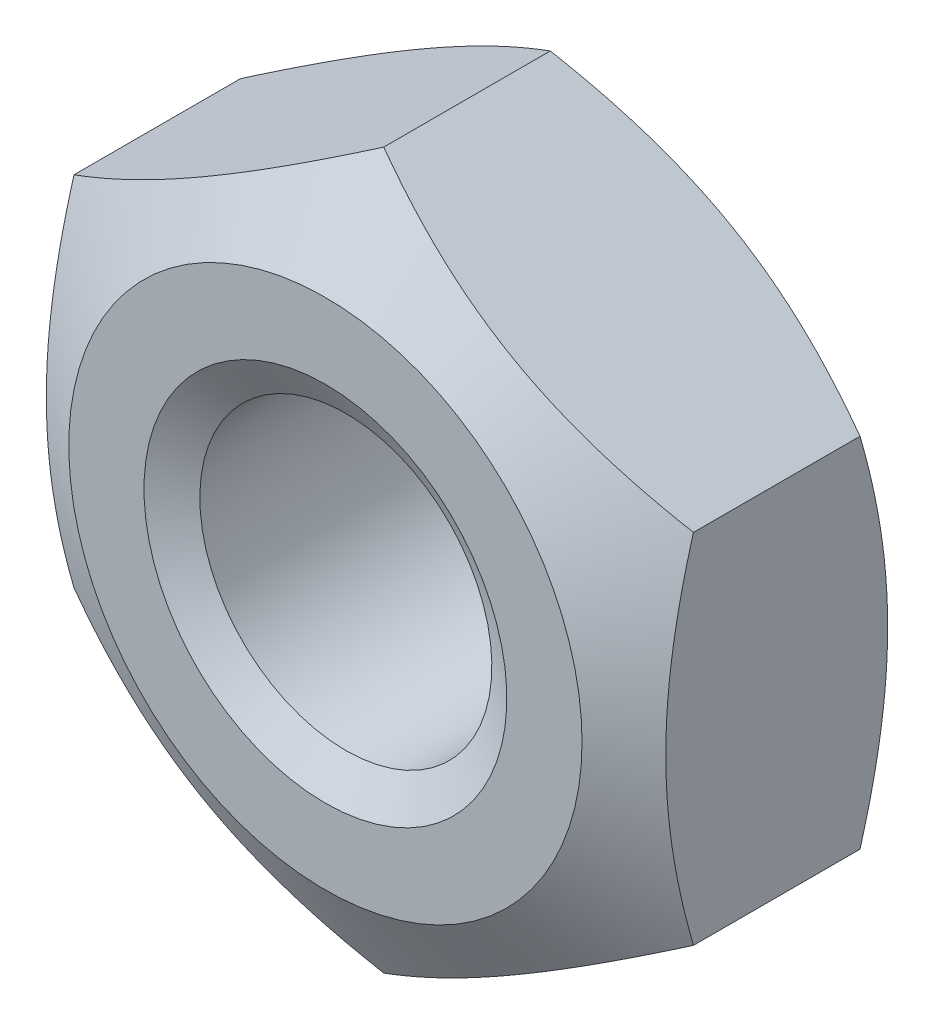
from build123d import *

# Parameters (mm, degrees)
BOSS_EXTRUDE1_DEPTH = 3.2


with BuildPart() as part:
    # Sketch1 → Boss-Extrude1 (new body)
    with BuildSketch(Plane.XY):
        Polygon((0, 4.041451884), (-3.5, 2.020725942), (-3.5, -2.020725942), (0, -4.041451884), (3.5, -2.020725942), (3.5, 2.020725942), align=None)
    extrude(amount=-BOSS_EXTRUDE1_DEPTH)

    # Sketch4 → Cut-Revolve1 (revolve, cut)
    with BuildSketch(Plane(origin=(0, 0, 0), x_dir=(0, 0, -1), z_dir=(1, 0, 0))):
        Polygon((3.2, 4.041451884), (2.540982447, 4.041451884), (3.2, 2.9), align=None)
        Polygon((0, 4.041451884), (0.659017553, 4.041451884), (0, 2.9), align=None)
    revolve(axis=Axis((0, 0, 0), (0, 0, -1)), mode=Mode.SUBTRACT)

    # Sketch5 → Cut-Revolve2 (revolve, cut)
    with BuildSketch(Plane(origin=(0, 0, 0), x_dir=(0, 0, -1), z_dir=(1, 0, 0))):
        Polygon((0, 0), (0, 2.05), (0.230940108, 1.65), (2.969059892, 1.65), (3.2, 2.05), (3.2, 0), align=None)
    revolve(axis=Axis((0, 0, 0), (0, 0, -1)), mode=Mode.SUBTRACT)


solid = part.part
